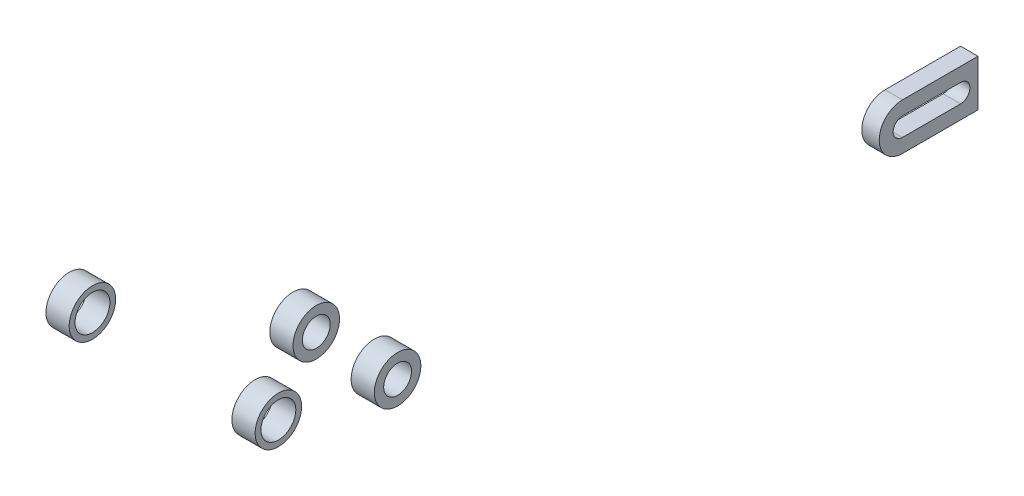
from build123d import *

# Parameters (mm, degrees)
RAMA_START               = -55
SZKIC_INSERT_RAMA_R      = 20
SZKIC_INSERT_RAMA_R_2    = 15
RAMA_DEPTH               = 10
LINKAGE_START            = 25
SZKIC_INSERT_LINKAGE_R   = 20
SZKIC_INSERT_LINKAGE_R_2 = 12
LINKAGE_DEPTH            = 20
TYLNE_KO_O_DEPTH         = 15


with BuildPart() as part:
    # Szkic - insert - rama → Rama (new, symmetric)
    with BuildSketch(Plane(origin=(135, 0, 0), x_dir=(0, 0, -1), z_dir=(1, 0, 0)).offset(RAMA_START)):
        Circle(SZKIC_INSERT_RAMA_R)
        Circle(SZKIC_INSERT_RAMA_R_2, mode=Mode.SUBTRACT)
    extrude(amount=RAMA_DEPTH, both=True)


with BuildPart() as body_2:
    # Szkic - insert - linkage → Linkage (new body)
    with BuildSketch(Plane(origin=(0, 0, 0), x_dir=(0, 0, -1), z_dir=(1, 0, 0)).offset(LINKAGE_START)):
        with Locations((147.6, -66)):
            Circle(SZKIC_INSERT_LINKAGE_R)
        with Locations((147.6, -66)):
            Circle(SZKIC_INSERT_LINKAGE_R_2, mode=Mode.SUBTRACT)
    extrude(amount=LINKAGE_DEPTH)


with BuildPart() as body_3:
    # Szkic - insert - tylne koło → Tylne koło (new body)
    with BuildSketch(Plane(origin=(125, 0, 0), x_dir=(0, 0, -1), z_dir=(1, 0, 0))):
        with BuildLine():
            Line((487, 20), (552, 20))
            Line((552, 20), (552, -20))
            Line((552, -20), (487, -20))
            ThreePointArc((487, -20), (467, 0), (487, 20))
        make_face()
        with BuildLine():
            Line((537, 8), (487, 8))
            ThreePointArc((487, 8), (479, 0), (487, -8))
            Line((487, -8), (537, -8))
            ThreePointArc((537, -8), (545, 0), (537, 8))
        make_face(mode=Mode.SUBTRACT)
    extrude(amount=TYLNE_KO_O_DEPTH)


with BuildPart() as body_4:
    # Lustro3: mirrored copy
    add(part.part.mirror(Plane(origin=(0, 0, 0), x_dir=(0, 0, 1), z_dir=(1, 0, 0))))


with BuildPart() as body_5:
    # Lustro3 2: mirrored copy
    add(body_2.part.mirror(Plane(origin=(0, 0, 0), x_dir=(0, 0, 1), z_dir=(1, 0, 0))))


solid = Compound([part.part, body_2.part, body_3.part, body_4.part, body_5.part])
